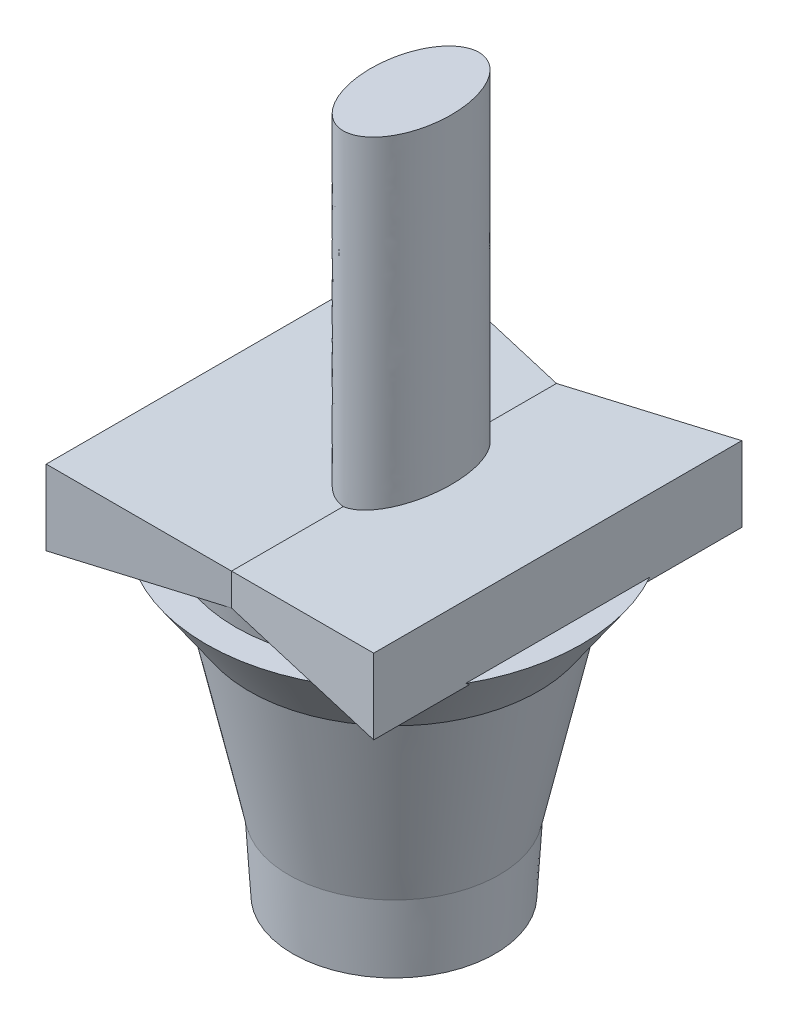
from build123d import *

# Parameters (mm, degrees)
CROQUIS2_R                        = 1.782924467
SALIENTE_EXTRUIR1_DEPTH           = 2
CROQUIS3_R                        = 4.136521179
CROQUIS5_W                        = 77.410053885
CROQUIS5_H                        = 7.627774641
SALIENTE_EXTRUIR2_DEPTH           = 39
SALIENTE_EXTRUIR2_TAPER           = -7.5
SALIENTE_EXTRUIR2_OTHER_WAY_DEPTH = 39
SALIENTE_EXTRUIR2_OTHER_WAY_TAPER = -7.5
CROQUIS7_RX                       = 16.173234621
CROQUIS7_RY                       = 9.593572243
SALIENTE_EXTRUIR3_DEPTH           = 78


with BuildPart() as part:
    # Croquis1 → Revolución1 (revolve)
    with BuildSketch(Plane(origin=(0, 0, 0), x_dir=(0, 0, -1), z_dir=(1, 0, 0)), mode=Mode.PRIVATE) as revoluci_n1_sk:
        Polygon((-15.602852663, 61.213506643), (-17.602852663, 61.213506643), (-13.213373125, -13.786493357), (-11.213373125, -13.786493357), align=None)
        Polygon((-16.203373125, -13.786493357), (-20.592852663, 61.213506643), (-22.592852663, 61.213506643), (-18.203373125, -13.786493357), align=None)
        Polygon((-21.193373125, -13.786493357), (-25.582852663, 61.213506643), (-27.582852663, 61.213506643), (-23.193373125, -13.786493357), align=None)
        Polygon((-30.572852663, 65.213506643), (-30.572852663, 61.213506643), (-26.183373125, -13.786493357), (-28.183373125, -13.786493357), (-29.164486203, 2.977107026), (-42.778871063, 64.846178561), align=None)
        Polygon((-10.60797751, 61.388785885), (-6.218497971, -13.611214115), (-8.218497971, -13.611214115), (-12.60797751, 61.388785885), align=None)
    revolve(revoluci_n1_sk.sketch.rotate(Axis((0, 0.969997308, 4.094639624), (0, 1, 0)), 180), axis=Axis((0, 0.969997308, 4.094639624), (0, 1, 0)))

    # Croquis5 → Saliente-Extruir2 (add)
    with BuildSketch(Plane(origin=(0, 0, 0), x_dir=(0, 0, -1), z_dir=(1, 0, 0))):
        with Locations((-4.073844121, 68.660065882)):
            Rectangle(CROQUIS5_W, CROQUIS5_H)
    extrude(amount=SALIENTE_EXTRUIR2_DEPTH, taper=SALIENTE_EXTRUIR2_TAPER)

    # Croquis5 → Saliente-Extruir2 other way (add)
    with BuildSketch(Plane(origin=(0, 0, 0), x_dir=(0, 0, -1), z_dir=(1, 0, 0))):
        with Locations((-4.073844121, 68.660065882)):
            Rectangle(CROQUIS5_W, CROQUIS5_H)
    extrude(amount=-SALIENTE_EXTRUIR2_OTHER_WAY_DEPTH, taper=SALIENTE_EXTRUIR2_OTHER_WAY_TAPER)

    # Croquis7 → Saliente-Extruir3 (add)
    with BuildSketch(Plane(origin=(0, 150, 0), x_dir=(1, 0, 0), z_dir=(0, 1, 0))):
        with Locations(Location((0, 0), (0, 0, -90))):
            Ellipse(CROQUIS7_RX, CROQUIS7_RY)
    extrude(amount=-SALIENTE_EXTRUIR3_DEPTH)

    # Croquis8 → Revolución4 (revolve)
    with BuildSketch(Plane(origin=(0, 0, 0), x_dir=(0, 0, -1), z_dir=(1, 0, 0)), mode=Mode.PRIVATE) as revoluci_n4_sk:
        Polygon((-41.802662251, 60.409905205), (-48.836532961, 60.409905205), (-38.53064276, 45.540573244), align=None)
    revolve(revoluci_n4_sk.sketch.rotate(Axis((0, -13.786493357, 4.094639624), (0, 1, 0)), 48.862979135), axis=Axis((0, -13.786493357, 4.094639624), (0, 1, 0)))


with BuildPart() as body_2:
    # Croquis2 → Saliente-Extruir1 (new body)
    with BuildSketch(Plane(origin=(0, 0, 0), x_dir=(1, 0, 0), z_dir=(0, 1, 0))):
        with Locations(Location((0, -4.094639624, 0), (0, 0, 270))):
            Circle(CROQUIS2_R)
    extrude(amount=SALIENTE_EXTRUIR1_DEPTH)

    # Croquis3 → section 1 of recubrir1
    with BuildSketch(Plane(origin=(0, 62, 0), x_dir=(-1, 0, 0), z_dir=(0, -1, 0)), mode=Mode.PRIVATE) as recubrir1_s1:
        with Locations((0, -4.094639624)):
            Circle(CROQUIS3_R)
    # loft up to a face of the part (recubrir1)
    loft([Face(Wire([body_2.edges().sort_by_distance((1.299696001, 2, 2.87414384))[0]])), recubrir1_s1.sketch])


solid = Compound([part.part, body_2.part])
